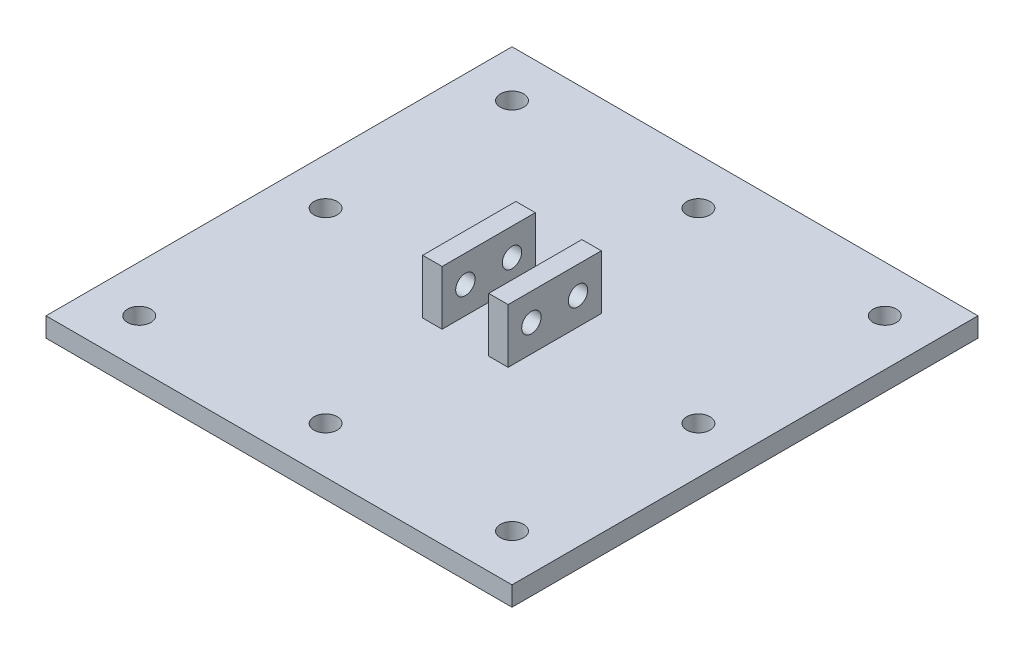
from build123d import *

# Parameters (mm, degrees)
SKETCH2_W           = 60
SKETCH2_H           = 60
BOSS_EXTRUDE1_DEPTH = 2.5
SKETCH3_W           = 2.5
SKETCH3_H           = 12
BOSS_EXTRUDE3_DEPTH = 7
SKETCH6_R           = 1.25
CUT_EXTRUDE1_DEPTH  = 11
CUT_EXTRUDE2_REACH  = 4.5
SKETCH7_R           = 1.5


with BuildPart() as part:
    # Sketch2 → Boss-Extrude1 (new body)
    with BuildSketch(Plane(origin=(0, 0, 0), x_dir=(1, 0, 0), z_dir=(0, 1, 0))):
        Rectangle(SKETCH2_W, SKETCH2_H)
    extrude(amount=BOSS_EXTRUDE1_DEPTH)

    # Sketch3 → Boss-Extrude3 (add)
    with BuildSketch(Plane(origin=(0, 2.5, 0), x_dir=(1, 0, 0), z_dir=(0, 1, 0))):
        with Locations((-4.25, 0)):
            Rectangle(SKETCH3_W, SKETCH3_H)
        with Locations((4.25, 0)):
            Rectangle(SKETCH3_W, SKETCH3_H)
    extrude(amount=BOSS_EXTRUDE3_DEPTH)

    # Sketch6 → Cut-Extrude1 (cut)
    with BuildSketch(Plane.ZY.offset(5.5)):
        with Locations((-3, 6)):
            Circle(SKETCH6_R)
        with Locations((3, 6)):
            Circle(SKETCH6_R)
    extrude(amount=-CUT_EXTRUDE1_DEPTH, mode=Mode.SUBTRACT)

    # Sketch7 → Cut-Extrude2 (cut, up to next)
    with BuildSketch(Plane(origin=(0, 2.5, 0), x_dir=(1, 0, 0), z_dir=(0, 1, 0)), mode=Mode.PRIVATE) as cut_extrude2_sk1:
        with Locations((24, -24)):
            Circle(SKETCH7_R)
    cut_extrude2_tool1 = extrude(cut_extrude2_sk1.sketch, amount=-CUT_EXTRUDE2_REACH, mode=Mode.PRIVATE) & part.part
    add(cut_extrude2_tool1.solids().sort_by_distance((24, 2.5, 24))[0], mode=Mode.SUBTRACT)
    # Sketch7 → Cut-Extrude2 (cut, up to next)
    with BuildSketch(Plane(origin=(0, 2.5, 0), x_dir=(1, 0, 0), z_dir=(0, 1, 0)), mode=Mode.PRIVATE) as cut_extrude2_sk2:
        with Locations((-24, -24)):
            Circle(SKETCH7_R)
    cut_extrude2_tool2 = extrude(cut_extrude2_sk2.sketch, amount=-CUT_EXTRUDE2_REACH, mode=Mode.PRIVATE) & part.part
    add(cut_extrude2_tool2.solids().sort_by_distance((-24, 2.5, 24))[0], mode=Mode.SUBTRACT)
    # Sketch7 → Cut-Extrude2 (cut, up to next)
    with BuildSketch(Plane(origin=(0, 2.5, 0), x_dir=(1, 0, 0), z_dir=(0, 1, 0)), mode=Mode.PRIVATE) as cut_extrude2_sk3:
        with Locations((-24, 24)):
            Circle(SKETCH7_R)
    cut_extrude2_tool3 = extrude(cut_extrude2_sk3.sketch, amount=-CUT_EXTRUDE2_REACH, mode=Mode.PRIVATE) & part.part
    add(cut_extrude2_tool3.solids().sort_by_distance((-24, 2.5, -24))[0], mode=Mode.SUBTRACT)
    # Sketch7 → Cut-Extrude2 (cut, up to next)
    with BuildSketch(Plane(origin=(0, 2.5, 0), x_dir=(1, 0, 0), z_dir=(0, 1, 0)), mode=Mode.PRIVATE) as cut_extrude2_sk4:
        with Locations((24, 24)):
            Circle(SKETCH7_R)
    cut_extrude2_tool4 = extrude(cut_extrude2_sk4.sketch, amount=-CUT_EXTRUDE2_REACH, mode=Mode.PRIVATE) & part.part
    add(cut_extrude2_tool4.solids().sort_by_distance((24, 2.5, -24))[0], mode=Mode.SUBTRACT)
    # Sketch7 → Cut-Extrude2 (cut, up to next)
    with BuildSketch(Plane(origin=(0, 2.5, 0), x_dir=(1, 0, 0), z_dir=(0, 1, 0)), mode=Mode.PRIVATE) as cut_extrude2_sk5:
        with Locations((24, 0)):
            Circle(SKETCH7_R)
    cut_extrude2_tool5 = extrude(cut_extrude2_sk5.sketch, amount=-CUT_EXTRUDE2_REACH, mode=Mode.PRIVATE) & part.part
    add(cut_extrude2_tool5.solids().sort_by_distance((24, 2.5, 0))[0], mode=Mode.SUBTRACT)
    # Sketch7 → Cut-Extrude2 (cut, up to next)
    with BuildSketch(Plane(origin=(0, 2.5, 0), x_dir=(1, 0, 0), z_dir=(0, 1, 0)), mode=Mode.PRIVATE) as cut_extrude2_sk6:
        with Locations((-24, 0)):
            Circle(SKETCH7_R)
    cut_extrude2_tool6 = extrude(cut_extrude2_sk6.sketch, amount=-CUT_EXTRUDE2_REACH, mode=Mode.PRIVATE) & part.part
    add(cut_extrude2_tool6.solids().sort_by_distance((-24, 2.5, 0))[0], mode=Mode.SUBTRACT)
    # Sketch7 → Cut-Extrude2 (cut, up to next)
    with BuildSketch(Plane(origin=(0, 2.5, 0), x_dir=(1, 0, 0), z_dir=(0, 1, 0)), mode=Mode.PRIVATE) as cut_extrude2_sk7:
        with Locations((0, -24)):
            Circle(SKETCH7_R)
    cut_extrude2_tool7 = extrude(cut_extrude2_sk7.sketch, amount=-CUT_EXTRUDE2_REACH, mode=Mode.PRIVATE) & part.part
    add(cut_extrude2_tool7.solids().sort_by_distance((0, 2.5, 24))[0], mode=Mode.SUBTRACT)
    # Sketch7 → Cut-Extrude2 (cut, up to next)
    with BuildSketch(Plane(origin=(0, 2.5, 0), x_dir=(1, 0, 0), z_dir=(0, 1, 0)), mode=Mode.PRIVATE) as cut_extrude2_sk8:
        with Locations((0, 24)):
            Circle(SKETCH7_R)
    cut_extrude2_tool8 = extrude(cut_extrude2_sk8.sketch, amount=-CUT_EXTRUDE2_REACH, mode=Mode.PRIVATE) & part.part
    add(cut_extrude2_tool8.solids().sort_by_distance((0, 2.5, -24))[0], mode=Mode.SUBTRACT)


solid = part.part
